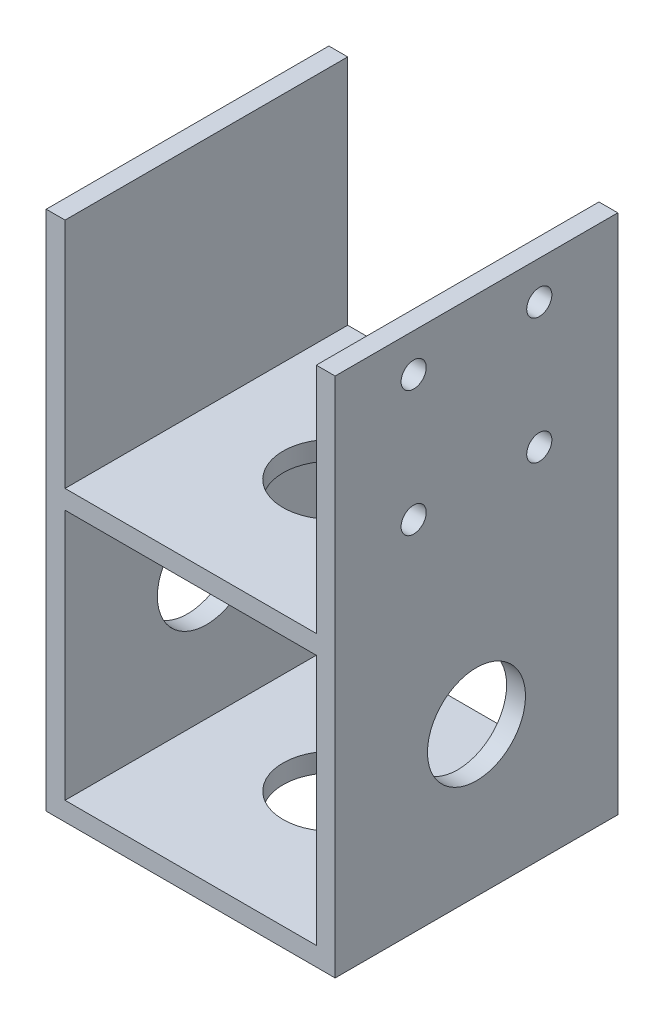
from build123d import *

# Parameters (mm, degrees)
SKETCH1_W           = 46
SKETCH1_H           = 45
BOSS_EXTRUDE1_DEPTH = 3
SKETCH5_W           = 3
SKETCH5_H           = 45
BOSS_EXTRUDE3_DEPTH = 35
SKETCH9_R           = 7.8
CUT_EXTRUDE5_DEPTH  = 10
SKETCH11_R          = 7.8
CUT_EXTRUDE8_DEPTH  = 47
SKETCH12_W          = 3
SKETCH12_H          = 45
BOSS_EXTRUDE4_DEPTH = 45
SKETCH13_R          = 2
CUT_EXTRUDE9_DEPTH  = 10


with BuildPart() as part:
    # Sketch1 → Boss-Extrude1 (new body)
    with BuildSketch(Plane(origin=(0, 0, 0), x_dir=(1, 0, 0), z_dir=(0, 1, 0))):
        Rectangle(SKETCH1_W, SKETCH1_H)
    boss_extrude1 = extrude(amount=BOSS_EXTRUDE1_DEPTH)

    # Sketch5 → Boss-Extrude3 (add)
    with BuildSketch(Plane(origin=(0, 3, 0), x_dir=(1, 0, 0), z_dir=(0, 1, 0))):
        with Locations((21.5, 0)):
            Rectangle(SKETCH5_W, SKETCH5_H)
        with Locations((-21.5, 0)):
            Rectangle(SKETCH5_W, SKETCH5_H)
    extrude(amount=BOSS_EXTRUDE3_DEPTH)

    # Sketch9 → Cut-Extrude5 (cut)
    with BuildSketch(Plane(origin=(0, 3, 0), x_dir=(1, 0, 0), z_dir=(0, 1, 0))):
        Circle(SKETCH9_R)
    cut_extrude5 = extrude(amount=-CUT_EXTRUDE5_DEPTH, mode=Mode.SUBTRACT)

    # Sketch11 → Cut-Extrude8 (cut, through all)
    with BuildSketch(Plane.ZY.offset(23)):
        with Locations((0, 23.75)):
            Circle(SKETCH11_R)
    extrude(amount=-CUT_EXTRUDE8_DEPTH, mode=Mode.SUBTRACT)

    # Sketch12 → Boss-Extrude4 (add)
    with BuildSketch(Plane(origin=(0, 38, 0), x_dir=(1, 0, 0), z_dir=(0, 1, 0))):
        with Locations((-21.5, 0)):
            Rectangle(SKETCH12_W, SKETCH12_H)
        with Locations((21.5, 0)):
            Rectangle(SKETCH12_W, SKETCH12_H)
    extrude(amount=BOSS_EXTRUDE4_DEPTH)

    # Sketch13 → Cut-Extrude9 (cut)
    with BuildSketch(Plane(origin=(23, 0, 0), x_dir=(0, 0, -1), z_dir=(1, 0, 0))):
        with Locations((-10, 76.955662999)):
            Circle(SKETCH13_R)
        with Locations((10, 76.955662999)):
            Circle(SKETCH13_R)
        with Locations((10, 56.955662999)):
            Circle(SKETCH13_R)
        with Locations((-10, 56.955662999)):
            Circle(SKETCH13_R)
    extrude(amount=-CUT_EXTRUDE9_DEPTH, mode=Mode.SUBTRACT)

    # Mirror1: Boss-Extrude1, Cut-Extrude5 across plane
    add(boss_extrude1.mirror(Plane.ZX.offset(23)))
    add(cut_extrude5.mirror(Plane.ZX.offset(23)), mode=Mode.SUBTRACT)


solid = part.part
